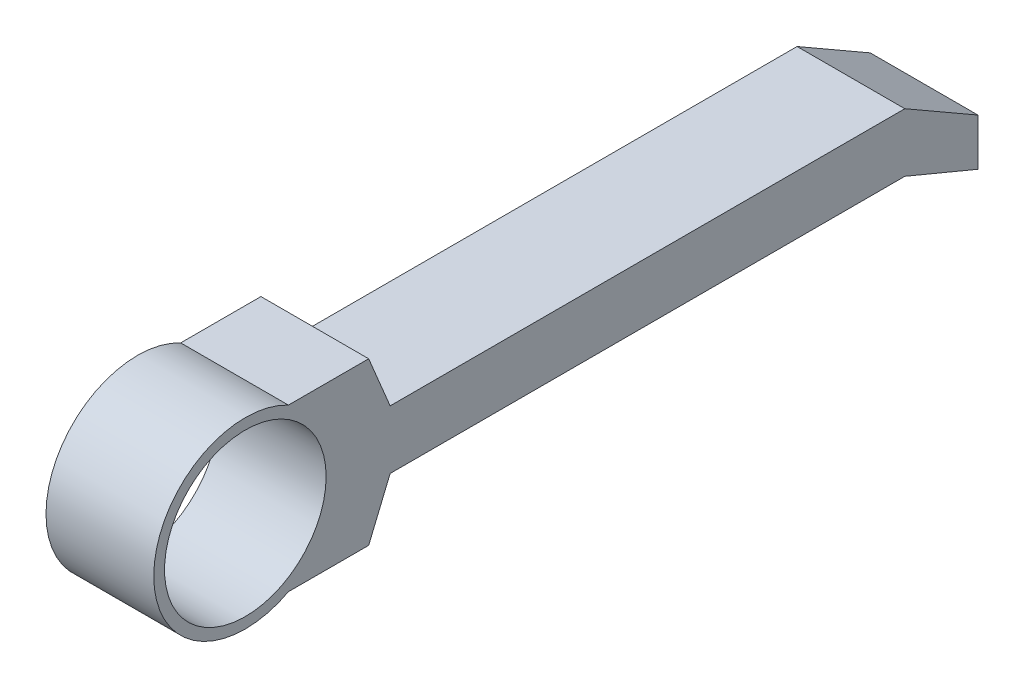
from build123d import *

# Parameters (mm, degrees)
CROQUIS2_R              = 1.5
SALIENTE_EXTRUIR1_DEPTH = 2


with BuildPart() as part:
    # Croquis2 → Saliente-Extruir1 (new body)
    with BuildSketch(Plane(origin=(0, 0, 0), x_dir=(0, 0, -1), z_dir=(1, 0, 0))):
        with BuildLine():
            Line((2.289585189, 1.5), (0.8, 1.5))
            ThreePointArc((0.8, 1.5), (-1.7, 0), (0.8, -1.5))
            Line((0.8, -1.5), (2.289585189, -1.5))
            Line((2.289585189, -1.5), (2.688008385, -0.543556392))
            Line((2.688008385, -0.543556392), (12.241709619, -0.543556392))
            Line((12.241709619, -0.543556392), (13.6, -1.109375841))
            Line((13.6, -1.109375841), (13.6, -0.237921662))
            Line((13.6, -0.237921662), (12.241709619, 0.543556392))
            Line((12.241709619, 0.543556392), (2.688008385, 0.543556392))
            Line((2.688008385, 0.543556392), (2.289585189, 1.5))
        make_face()
        Circle(CROQUIS2_R, mode=Mode.SUBTRACT)
    extrude(amount=SALIENTE_EXTRUIR1_DEPTH)


solid = part.part
